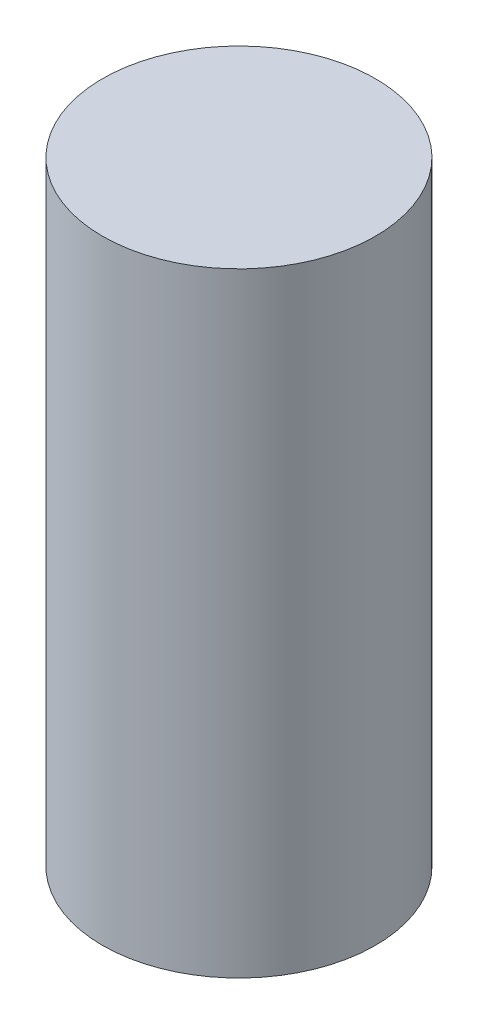
from build123d import *

# Parameters (mm, degrees)
SKETCH1_R           = 5
BOSS_EXTRUDE1_DEPTH = 22.5
SCALE1_SCALE        = 0.66


with BuildPart() as part:
    # Sketch1 → Boss-Extrude1 (new body)
    with BuildSketch(Plane(origin=(0, 0, 0), x_dir=(1, 0, 0), z_dir=(0, 1, 0))):
        Circle(SKETCH1_R)
    extrude(amount=BOSS_EXTRUDE1_DEPTH)


with BuildPart() as part_1:
    # Scale1: scaled about (0, 11.25, 0)
    add(part.part.scale(SCALE1_SCALE).moved(Location((0, 3.825, 0))))


solid = part_1.part
